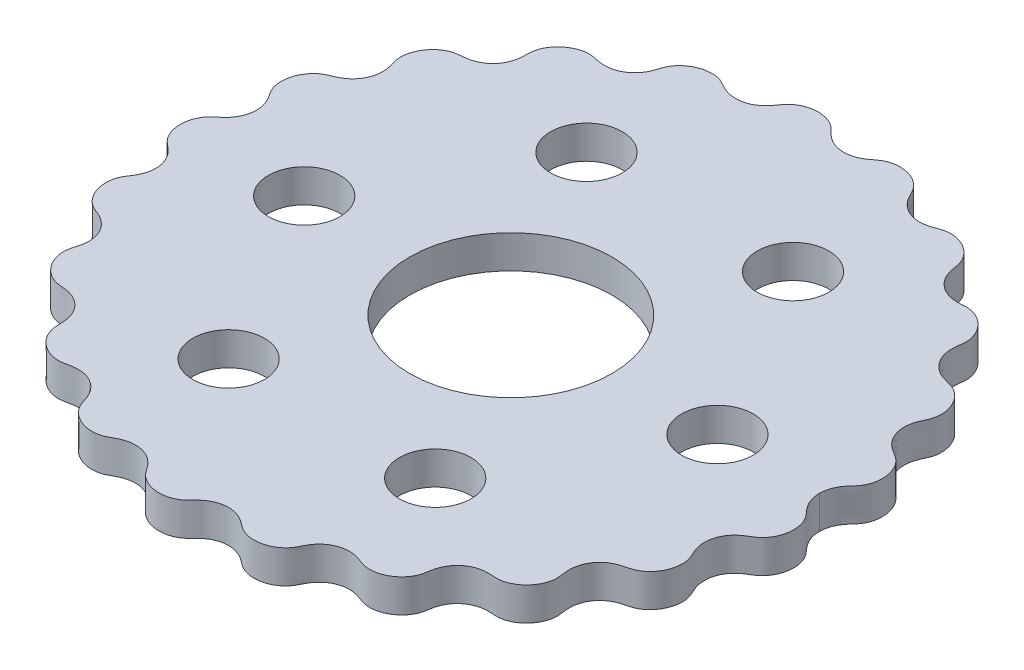
from build123d import *

# Parameters (mm, degrees)
BOSS_EXTRUDE1_DEPTH = 6
SKETCH1_3_R         = 6.499999995
SKETCH1_3_R_2       = 6.5
SKETCH1_3_R_3       = 18.35
CUT_EXTRUDE1_DEPTH  = 10


with BuildPart() as part:
    # Sketch1 → Boss-Extrude1 (new body)
    with BuildSketch(Plane(origin=(0, 0, 0), x_dir=(1, 0, 0), z_dir=(0, 1, 0))):
        with BuildLine():
            add(Edge.make_bspline(
                [(57.735944512, -0.872122044), (57.735944512, -0.912212203), (57.736738727, -0.972761677), (57.739386016, -1.070626494), (57.746529787, -1.218500914), (57.756842538, -1.360557169), (57.778238993, -1.563968995), (57.819349911, -1.8401656), (57.88548079, -2.15737421), (57.985469515, -2.514430558), (58.109192571, -2.863825131), (58.255774209, -3.204314775), (58.439313111, -3.564253825), (58.665041521, -3.939072399), (58.937227781, -4.323417519), (59.257113709, -4.713188169), (59.596216116, -5.085841283), (59.935832468, -5.458156017), (60.321448968, -5.957623654), (60.660412171, -6.560317653), (60.924520674, -7.26264891), (61.130021505, -8.233669578), (61.172438222, -9.330269063), (60.971644645, -10.584052184), (60.457888936, -11.820158958), (59.751390937, -12.811048088), (58.912704498, -13.548646168), (58.025238215, -14.025072447), (57.095836274, -14.630243544), (56.210672318, -15.470016863), (55.468778936, -16.594981463), (55.011108602, -17.996150612), (54.95102907, -19.367392247), (55.199905823, -20.60928829), (55.627429749, -21.664568498), (56.102964052, -22.566683019), (56.398061139, -23.673845432), (56.42381368, -24.937921243), (56.128527227, -26.29862313), (55.456042739, -27.66009111), (54.556835907, -28.713315085), (53.546186084, -29.447687439), (52.522388993, -29.865724156), (51.581127732, -30.046727679), (50.565154627, -30.348156548), (49.518690192, -30.863427986), (48.510459691, -31.676554528), (47.666134915, -32.819468032), (47.227174646, -33.944291547), (47.064115224, -34.916155192), (47.043602858, -35.662776892), (47.069766109, -36.173865589), (47.128796074, -36.682126487), (47.205617683, -37.187527633), (47.261543689, -37.69638347), (47.263503677, -38.208867841), (47.202838729, -38.786102225), (47.056851433, -39.418642443), (46.806467548, -40.091238655), (46.434535885, -40.783309802), (45.885154277, -41.546310703), (45.108545478, -42.32228952), (44.159402874, -42.956439291), (43.169472964, -43.340339326), (42.359287119, -43.489476361), (41.770894189, -43.517161226), (41.300569004, -43.496819045), (40.83151896, -43.462165835), (40.361279877, -43.442671125), (39.825032507, -43.45121541), (39.225611134, -43.511724289), (38.391858629, -43.688891111), (37.351540163, -44.108327995), (36.263876611, -44.872724784), (35.381852604, -45.966684533), (34.896973212, -47.019335582), (34.6632779, -47.886745748), (34.549108202, -48.520553976), (34.4731394, -49.029773683), (34.371008537, -49.535238619), (34.214413373, -50.026992804), (33.903423413, -50.729011324), (33.335284446, -51.581848222), (32.416671056, -52.477050512), (31.086759448, -53.24487207), (29.852185249, -53.592820172), (28.829539318, -53.658415025), (28.066073632, -53.576745469), (27.561916514, -53.466452347), (27.073078134, -53.302236719), (26.594147963, -53.113290995), (26.109286632, -52.939054616), (25.614185631, -52.795592392), (24.861473136, -52.640240085), (23.837167339, -52.577707768), (22.577563461, -52.774513346), (21.203612679, -53.412335488), (20.257244364, -54.223525605), (19.659966292, -54.990514254), (19.290519118, -55.607941334), (19.072196467, -56.024896366), (18.867677329, -56.448433209), (18.650218254, -56.865944371), (18.395531547, -57.26247376), (18.102339269, -57.631308947), (17.612836095, -58.13731666), (16.863938685, -58.706586604), (15.946493884, -59.158964571), (14.886248164, -59.443562542), (13.950735689, -59.537826542), (13.165445357, -59.513901814), (12.457749956, -59.394436713), (11.836971546, -59.204598888), (11.306732789, -58.968516949), (10.863892494, -58.710578712), (10.451170545, -58.407716529), (10.051892994, -58.088487093), (9.64124005, -57.783234849), (9.2117064, -57.505032628), (8.554856636, -57.149485937), (7.631668445, -56.804767756), (6.438062489, -56.622506716), (5.026108025, -56.782256687), (3.817804499, -57.248846631), (2.848334152, -57.897475706), (2.079302519, -58.626619781), (1.451918262, -59.351274194), (0.57798927, -60.028890109), (-0.563320709, -60.536952377), (-1.925042919, -60.789076309), (-3.440350903, -60.690731034), (-4.766396711, -60.266105561), (-5.848241922, -59.611765455), (-6.659524625, -58.802622419), (-7.203010634, -57.939740878), (-7.903149893, -57.041853241), (-8.854222231, -56.205373154), (-10.071796408, -55.57178039), (-11.514072998, -55.267553567), (-12.859278031, -55.347564121), (-14.029107751, -55.694261327), (-15.017932918, -56.196544811), (-15.874210077, -56.726928966), (-16.93241733, -57.084407226), (-18.143665008, -57.20088243), (-19.471263482, -57.027632692), (-20.830962065, -56.508441969), (-21.949539292, -55.739698074), (-22.789864401, -54.811949147), (-23.337820973, -53.816670143), (-23.607575092, -52.842506939), (-23.993634766, -51.782987105), (-24.634422102, -50.703280147), (-25.596944973, -49.715571049), (-26.897278391, -48.964823199), (-28.233921, -48.625108492), (-29.489368317, -48.610023857), (-30.599969255, -48.805446291), (-31.578496382, -49.058913971), (-32.714411594, -49.082009165), (-33.938028246, -48.818140732), (-35.16306867, -48.233796392), (-36.292550209, -47.315858226), (-37.106388289, -46.252749111), (-37.611141372, -45.145540218), (-37.830660198, -44.050366777), (-37.799471735, -43.043616825), (-37.858895723, -41.936127558), (-38.143559404, -40.749676403), (-38.746874685, -39.544689846), (-39.73147495, -38.447754381), (-40.888979247, -37.710101716), (-42.088912713, -37.304687154), (-43.216603451, -37.147295752), (-44.235575929, -37.108058346), (-45.342034082, -36.810047417), (-46.449501647, -36.200297112), (-47.480480819, -35.264245688), (-48.322930922, -34.001080317), (-48.786027399, -32.695798932), (-48.915807599, -31.453263499), (-48.783605959, -30.477202417), (-48.569056481, -29.79149327), (-48.370031316, -29.102592293), (-48.196749635, -28.301208567), (-48.129295501, -27.257613402), (-48.328327945, -25.977777634), (-48.896654807, -24.675194082), (-49.650822286, -23.732576776), (-50.411248392, -23.105465419), (-51.047405352, -22.714369683), (-51.50322333, -22.481497192), (-51.972823813, -22.278478869), (-52.448973367, -22.092313321), (-52.917592556, -21.886315779), (-53.362409605, -21.631772429), (-53.831970144, -21.290617099), (-54.306776344, -20.847918723), (-54.764067427, -20.294781559), (-55.177454117, -19.62664384), (-55.563540712, -18.769364921), (-55.847254237, -17.708812544), (-55.921872324, -16.569756141), (-55.759374852, -15.520501508), (-55.483438182, -14.744291725), (-55.213217717, -14.220885592), (-54.96043793, -13.823744276), (-54.695902999, -13.434859211), (-54.443899469, -13.03737174), (-54.183177047, -12.568689006), (-53.935866257, -12.019330121), (-53.672424133, -11.208680926), (-53.542372795, -10.288215827), (-53.582139451, -9.351245196), (-53.794007128, -8.433845838), (-54.069222754, -7.719484739), (-54.473284107, -6.991888273), (-54.944169242, -6.381470655), (-55.443603747, -5.880704979), (-55.935377258, -5.464961136), (-56.338408701, -5.14449574), (-56.725082032, -4.803419862), (-57.072651717, -4.421773822), (-57.356834529, -4.032389724), (-57.585450175, -3.646902824), (-57.76736029, -3.274945566), (-57.910199635, -2.922328872), (-58.02903601, -2.561190262), (-58.123929309, -2.192599588), (-58.18613498, -1.866351285), (-58.224610447, -1.582070942), (-58.244582269, -1.37333142), (-58.254196265, -1.227990672), (-58.260851438, -1.076047408), (-58.26331609, -0.974887053), (-58.264055488, -0.913255953), (-58.264055488, -0.872122044)],
                knots=[0.065447189, 0.065447189, 0.065447189, 0.065447189, 0.065447189, 0.066221163, 0.06660815, 0.066995138, 0.067769112, 0.068543087, 0.070091036, 0.071638985, 0.073186934, 0.074734883, 0.076282832, 0.077830781, 0.079936354, 0.082041927, 0.084147499, 0.086253072, 0.088358645, 0.090464217, 0.094675363, 0.097759031, 0.100842698, 0.107010034, 0.112905453, 0.118800871, 0.122997839, 0.127194808, 0.131391776, 0.135588745, 0.141508176, 0.147427607, 0.153674665, 0.159921724, 0.164170826, 0.168419929, 0.172669031, 0.176918134, 0.183140404, 0.189362675, 0.195705197, 0.202047719, 0.206045142, 0.210042565, 0.214039988, 0.218037411, 0.223723011, 0.229408612, 0.235466844, 0.241525076, 0.243662031, 0.245798985, 0.24793594, 0.250072894, 0.252209849, 0.254346803, 0.256483758, 0.258620712, 0.261894302, 0.265167892, 0.268441482, 0.271715072, 0.277567256, 0.28341944, 0.287351254, 0.289317161, 0.291283067, 0.293248974, 0.295214881, 0.297180788, 0.299146694, 0.302207803, 0.305268911, 0.311391127, 0.317768019, 0.324144911, 0.32844912, 0.330601225, 0.33275333, 0.334905435, 0.337057539, 0.339209644, 0.341361749, 0.347714749, 0.354067749, 0.360420749, 0.366773749, 0.368925854, 0.371077958, 0.373230063, 0.375382168, 0.377534273, 0.379686377, 0.381838482, 0.383990587, 0.390367479, 0.39674437, 0.402866587, 0.408988803, 0.41095471, 0.412920617, 0.414886524, 0.41685243, 0.418818337, 0.420784244, 0.422750151, 0.424716058, 0.430568242, 0.436420426, 0.439694016, 0.442967606, 0.446241196, 0.449514785, 0.45165174, 0.453788695, 0.455925649, 0.458062604, 0.460199558, 0.462336513, 0.464473467, 0.466610422, 0.472668654, 0.478726886, 0.484412486, 0.490098087, 0.49409551, 0.498092933, 0.502090356, 0.506087779, 0.512430301, 0.518772823, 0.524995093, 0.531217364, 0.535466466, 0.539715569, 0.543964672, 0.548213774, 0.554460832, 0.56070789, 0.566627322, 0.572546753, 0.576743721, 0.58094069, 0.585137658, 0.589334627, 0.595230045, 0.601125463, 0.607292799, 0.613460135, 0.61767128, 0.621882426, 0.626093571, 0.630304717, 0.636496513, 0.642688309, 0.648880105, 0.655071902, 0.659283047, 0.663494192, 0.667705338, 0.671916483, 0.678083819, 0.684251155, 0.690146573, 0.696041991, 0.70023896, 0.704435928, 0.708632897, 0.712829865, 0.718749296, 0.724668728, 0.730915786, 0.737162844, 0.741411947, 0.745661049, 0.749910152, 0.754159255, 0.760381525, 0.766603795, 0.772946317, 0.779288839, 0.783286262, 0.787283685, 0.789282397, 0.791281108, 0.795278531, 0.800964132, 0.806649732, 0.812707964, 0.818766196, 0.820903151, 0.823040105, 0.82517706, 0.827314014, 0.829450969, 0.831587924, 0.833724878, 0.835861833, 0.839135423, 0.842409012, 0.845682602, 0.848956192, 0.854808376, 0.860660561, 0.864592374, 0.866558281, 0.868524188, 0.870490094, 0.872456001, 0.874421908, 0.876387815, 0.879448923, 0.882510031, 0.888632248, 0.891820694, 0.89500914, 0.898197585, 0.901386031, 0.905690241, 0.907842346, 0.90999445, 0.912146555, 0.91429866, 0.916450764, 0.918602869, 0.920191119, 0.921779369, 0.923367619, 0.924955869, 0.926544119, 0.928132369, 0.928926494, 0.929720619, 0.930117682, 0.930514744, 0.931308869, 0.931308869, 0.931308869, 0.931308869, 0.931308869], degree=4))
            add(Edge.make_bspline(
                [(57.735944512, -0.872122044), (57.735944512, -0.832031884), (57.736738727, -0.77148241), (57.739386016, -0.673617592), (57.746529787, -0.525743173), (57.756842538, -0.383686917), (57.778238993, -0.180275092), (57.819349911, 0.095921514), (57.88548079, 0.413130123), (57.985469515, 0.770186472), (58.109192571, 1.119581045), (58.255774209, 1.460070688), (58.439313111, 1.820009738), (58.665041521, 2.194828313), (58.937227781, 2.579173433), (59.257113709, 2.968944083), (59.596216116, 3.341597196), (59.935832468, 3.71391193), (60.321448968, 4.213379567), (60.660412171, 4.816073566), (60.924520674, 5.518404823), (61.130021505, 6.489425491), (61.172438222, 7.586024976), (60.971644645, 8.839808098), (60.457888936, 10.075914871), (59.751390937, 11.066804001), (58.912704498, 11.804402081), (58.025238215, 12.28082836), (57.095836274, 12.885999458), (56.210672318, 13.725772776), (55.468778936, 14.850737376), (55.011108602, 16.251906525), (54.95102907, 17.62314816), (55.199905823, 18.865044203), (55.627429749, 19.920324412), (56.102964052, 20.822438932), (56.398061139, 21.929601345), (56.42381368, 23.193677156), (56.128527227, 24.554379043), (55.456042739, 25.915847023), (54.556835907, 26.969070998), (53.546186084, 27.703443353), (52.522388993, 28.121480069), (51.581127732, 28.302483593), (50.565154627, 28.603912462), (49.518690192, 29.1191839), (48.510459691, 29.932310441), (47.666134915, 31.075223945), (47.227174646, 32.200047461), (47.064115224, 33.171911106), (47.043602858, 33.918532805), (47.069766109, 34.429621503), (47.128796074, 34.9378824), (47.205617683, 35.443283546), (47.261543689, 35.952139384), (47.263503677, 36.464623754), (47.202838729, 37.041858138), (47.056851433, 37.674398356), (46.806467548, 38.346994569), (46.434535885, 39.039065715), (45.885154277, 39.802066616), (45.108545478, 40.578045434), (44.159402874, 41.212195204), (43.169472964, 41.596095239), (42.359287119, 41.745232274), (41.770894189, 41.772917139), (41.300569004, 41.752574959), (40.83151896, 41.717921748), (40.361279877, 41.698427038), (39.825032507, 41.706971323), (39.225611134, 41.767480202), (38.391858628, 41.944647024), (37.351540163, 42.364083908), (36.263876611, 43.128480697), (35.381852603, 44.222440446), (34.896973212, 45.275091495), (34.6632779, 46.142501661), (34.549108202, 46.776309889), (34.4731394, 47.285529597), (34.371008537, 47.790994532), (34.214413373, 48.282748717), (33.903423413, 48.984767237), (33.335284446, 49.837604135), (32.416671056, 50.732806425), (31.086759448, 51.500627983), (29.852185249, 51.848576085), (28.829539318, 51.914170938), (28.066073632, 51.832501383), (27.561916514, 51.72220826), (27.073078134, 51.557992633), (26.594147963, 51.369046908), (26.109286632, 51.19481053), (25.614185631, 51.051348306), (24.861473136, 50.895995998), (23.837167339, 50.833463681), (22.57756346, 51.030269259), (21.203612679, 51.668091401), (20.257244364, 52.479281518), (19.659966292, 53.246270167), (19.290519118, 53.863697247), (19.072196466, 54.280652279), (18.867677329, 54.704189122), (18.650218254, 55.121700284), (18.395531547, 55.518229673), (18.102339269, 55.887064861), (17.612836095, 56.393072573), (16.863938685, 56.962342517), (15.946493884, 57.414720484), (14.886248164, 57.699318455), (13.950735689, 57.793582456), (13.165445357, 57.769657727), (12.457749956, 57.650192626), (11.836971546, 57.460354801), (11.306732789, 57.224272862), (10.863892493, 56.966334625), (10.451170545, 56.663472442), (10.051892994, 56.344243007), (9.64124005, 56.038990762), (9.2117064, 55.760788541), (8.554856636, 55.40524185), (7.631668445, 55.060523669), (6.438062489, 54.878262629), (5.026108025, 55.0380126), (3.817804499, 55.504602544), (2.848334152, 56.153231619), (2.079302519, 56.882375694), (1.451918262, 57.607030107), (0.57798927, 58.284646022), (-0.563320709, 58.792708291), (-1.925042919, 59.044832223), (-3.440350903, 58.946486947), (-4.766396711, 58.521861475), (-5.848241922, 57.867521368), (-6.659524625, 57.058378332), (-7.203010634, 56.195496792), (-7.903149893, 55.297609154), (-8.854222231, 54.461129067), (-10.071796408, 53.827536303), (-11.514072998, 53.523309481), (-12.859278031, 53.603320034), (-14.029107751, 53.95001724), (-15.017932918, 54.452300724), (-15.874210077, 54.982684879), (-16.93241733, 55.340163139), (-18.143665008, 55.456638343), (-19.471263482, 55.283388605), (-20.830962065, 54.764197883), (-21.949539292, 53.995453987), (-22.789864401, 53.06770506), (-23.337820973, 52.072426056), (-23.607575092, 51.098262853), (-23.993634766, 50.038743018), (-24.634422102, 48.95903606), (-25.596944973, 47.971326962), (-26.897278391, 47.220579112), (-28.233921, 46.880864405), (-29.489368317, 46.86577977), (-30.599969255, 47.061202205), (-31.578496382, 47.314669884), (-32.714411594, 47.337765078), (-33.938028246, 47.073896645), (-35.16306867, 46.489552305), (-36.292550209, 45.571614139), (-37.106388289, 44.508505024), (-37.611141372, 43.401296131), (-37.830660198, 42.30612269), (-37.799471735, 41.299372738), (-37.858895723, 40.191883471), (-38.143559404, 39.005432316), (-38.746874685, 37.800445759), (-39.73147495, 36.703510295), (-40.888979247, 35.965857629), (-42.088912713, 35.560443067), (-43.216603451, 35.403051665), (-44.235575929, 35.363814259), (-45.342034082, 35.06580333), (-46.449501647, 34.456053025), (-47.480480819, 33.520001601), (-48.322930922, 32.25683623), (-48.786027399, 30.951554846), (-48.915807599, 29.709019412), (-48.783605959, 28.73295833), (-48.569056481, 28.047249183), (-48.370031316, 27.358348207), (-48.196749635, 26.55696448), (-48.129295502, 25.513369315), (-48.328327945, 24.233533547), (-48.896654807, 22.930949996), (-49.650822286, 21.988332689), (-50.411248392, 21.361221333), (-51.047405352, 20.970125596), (-51.50322333, 20.737253105), (-51.972823813, 20.534234782), (-52.448973367, 20.348069234), (-52.917592556, 20.142071692), (-53.362409605, 19.887528343), (-53.831970144, 19.546373012), (-54.306776344, 19.103674636), (-54.764067427, 18.550537472), (-55.177454117, 17.882399753), (-55.563540712, 17.025120835), (-55.847254237, 15.964568457), (-55.921872324, 14.825512054), (-55.759374852, 13.776257422), (-55.483438182, 13.000047639), (-55.213217717, 12.476641505), (-54.96043793, 12.079500189), (-54.695902999, 11.690615125), (-54.443899469, 11.293127654), (-54.183177047, 10.824444919), (-53.935866257, 10.275086034), (-53.672424133, 9.464436839), (-53.542372795, 8.543971741), (-53.582139451, 7.607001109), (-53.794007128, 6.689601751), (-54.069222754, 5.975240652), (-54.473284108, 5.247644186), (-54.944169242, 4.637226569), (-55.443603747, 4.136460892), (-55.935377258, 3.720717049), (-56.338408701, 3.400251653), (-56.725082032, 3.059175776), (-57.072651717, 2.677529736), (-57.356834529, 2.288145637), (-57.585450175, 1.902658738), (-57.76736029, 1.53070148), (-57.910199635, 1.178084785), (-58.02903601, 0.816946175), (-58.123929309, 0.448355502), (-58.18613498, 0.122107198), (-58.224610447, -0.162173145), (-58.244582269, -0.370912667), (-58.254196265, -0.516253415), (-58.260851438, -0.668196679), (-58.26331609, -0.769357034), (-58.264055488, -0.830988134), (-58.264055488, -0.872122044)],
                knots=[0.065447189, 0.065447189, 0.065447189, 0.065447189, 0.065447189, 0.066221163, 0.06660815, 0.066995138, 0.067769112, 0.068543087, 0.070091036, 0.071638985, 0.073186934, 0.074734883, 0.076282832, 0.077830781, 0.079936354, 0.082041927, 0.084147499, 0.086253072, 0.088358645, 0.090464217, 0.094675363, 0.097759031, 0.100842698, 0.107010034, 0.112905453, 0.118800871, 0.122997839, 0.127194808, 0.131391776, 0.135588745, 0.141508176, 0.147427607, 0.153674665, 0.159921724, 0.164170826, 0.168419929, 0.172669031, 0.176918134, 0.183140404, 0.189362675, 0.195705197, 0.202047719, 0.206045142, 0.210042565, 0.214039988, 0.218037411, 0.223723011, 0.229408612, 0.235466844, 0.241525076, 0.243662031, 0.245798985, 0.24793594, 0.250072894, 0.252209849, 0.254346803, 0.256483758, 0.258620712, 0.261894302, 0.265167892, 0.268441482, 0.271715072, 0.277567256, 0.28341944, 0.287351254, 0.289317161, 0.291283067, 0.293248974, 0.295214881, 0.297180788, 0.299146694, 0.302207803, 0.305268911, 0.311391127, 0.317768019, 0.324144911, 0.32844912, 0.330601225, 0.33275333, 0.334905435, 0.337057539, 0.339209644, 0.341361749, 0.347714749, 0.354067749, 0.360420749, 0.366773749, 0.368925854, 0.371077958, 0.373230063, 0.375382168, 0.377534273, 0.379686377, 0.381838482, 0.383990587, 0.390367479, 0.39674437, 0.402866587, 0.408988803, 0.41095471, 0.412920617, 0.414886524, 0.41685243, 0.418818337, 0.420784244, 0.422750151, 0.424716058, 0.430568242, 0.436420426, 0.439694016, 0.442967606, 0.446241196, 0.449514785, 0.45165174, 0.453788695, 0.455925649, 0.458062604, 0.460199558, 0.462336513, 0.464473467, 0.466610422, 0.472668654, 0.478726886, 0.484412486, 0.490098087, 0.49409551, 0.498092933, 0.502090356, 0.506087779, 0.512430301, 0.518772823, 0.524995093, 0.531217364, 0.535466466, 0.539715569, 0.543964672, 0.548213774, 0.554460832, 0.56070789, 0.566627322, 0.572546753, 0.576743721, 0.58094069, 0.585137658, 0.589334627, 0.595230045, 0.601125463, 0.607292799, 0.613460135, 0.61767128, 0.621882426, 0.626093571, 0.630304717, 0.636496513, 0.642688309, 0.648880105, 0.655071902, 0.659283047, 0.663494192, 0.667705338, 0.671916483, 0.678083819, 0.684251155, 0.690146573, 0.696041991, 0.70023896, 0.704435928, 0.708632897, 0.712829865, 0.718749296, 0.724668728, 0.730915786, 0.737162844, 0.741411947, 0.745661049, 0.749910152, 0.754159255, 0.760381525, 0.766603795, 0.772946317, 0.779288839, 0.783286262, 0.787283685, 0.789282397, 0.791281108, 0.795278531, 0.800964132, 0.806649732, 0.812707964, 0.818766196, 0.820903151, 0.823040105, 0.82517706, 0.827314014, 0.829450969, 0.831587924, 0.833724878, 0.835861833, 0.839135423, 0.842409012, 0.845682602, 0.848956192, 0.854808376, 0.860660561, 0.864592374, 0.866558281, 0.868524188, 0.870490094, 0.872456001, 0.874421908, 0.876387815, 0.879448923, 0.882510031, 0.888632248, 0.891820694, 0.89500914, 0.898197585, 0.901386031, 0.905690241, 0.907842346, 0.90999445, 0.912146555, 0.91429866, 0.916450764, 0.918602869, 0.920191119, 0.921779369, 0.923367619, 0.924955869, 0.926544119, 0.928132369, 0.928926494, 0.929720619, 0.930117682, 0.930514744, 0.931308869, 0.931308869, 0.931308869, 0.931308869, 0.931308869], degree=4))
        make_face()
    extrude(amount=BOSS_EXTRUDE1_DEPTH)

    # Sketch1_3 → Cut-Extrude1 (cut)
    with BuildSketch(Plane(origin=(0, 0, 0), x_dir=(1, 0, 0), z_dir=(0, 1, 0))):
        with Locations((-35.764055484, -0.872122039)):
            Circle(SKETCH1_3_R)
        with Locations((-17.014055488, 31.603830599)):
            Circle(SKETCH1_3_R_2)
        with Locations((20.485944512, 31.603830599)):
            Circle(SKETCH1_3_R_2)
        with Locations((39.235944512, -0.872122043)):
            Circle(SKETCH1_3_R_2)
        with Locations((20.485944512, -33.348074685)):
            Circle(SKETCH1_3_R_2)
        with Locations((-17.014055488, -33.348074685)):
            Circle(SKETCH1_3_R_2)
        with Locations((1.735944516, -0.872122039)):
            Circle(SKETCH1_3_R_3)
    extrude(amount=CUT_EXTRUDE1_DEPTH, mode=Mode.SUBTRACT)


solid = part.part
